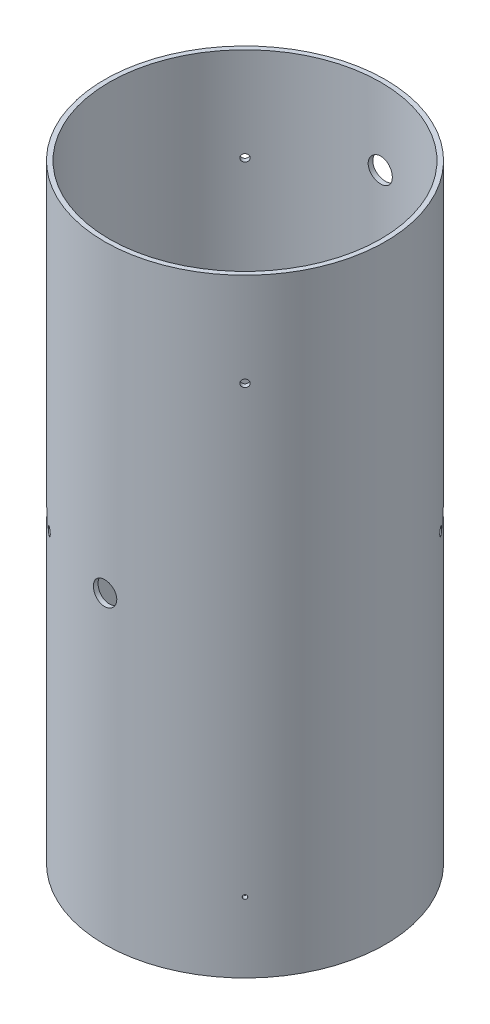
from build123d import *

# Parameters (mm, degrees)
SKETCH1_R               = 76.1746
SKETCH1_R_2             = 73.66
BOSS_EXTRUDE1_DEPTH     = 330.2
SKETCH27_R              = 6.35
CUT_EXTRUDE1_DEPTH      = 77.1746001
CUT_EXTRUDE1_DEPTH_BACK = 77.1746001
SKETCH30_R              = 2.18313
SKETCH30_W              = 9.906
SKETCH30_H              = 9.906
CUT_EXTRUDE2_DEPTH      = 108.72715257
CUT_EXTRUDE2_DEPTH_BACK = 108.72715257
SKETCH23_R              = 1.0922
SHEAR_SCRREWS_DEPTH     = 108.72715257
CIRPATTERN1_COUNT       = 4
CIRPATTERN2_COUNT       = 4


with BuildPart() as part:
    # Sketch1 → Boss-Extrude1 (new body)
    with BuildSketch(Plane(origin=(0, 0, 0), x_dir=(1, 0, 0), z_dir=(0, 1, 0))):
        Circle(SKETCH1_R)
        Circle(SKETCH1_R_2, mode=Mode.SUBTRACT)
    extrude(amount=BOSS_EXTRUDE1_DEPTH)

    # Sketch17 → 1/2 Clearance Hole5 (revolve, cut)
    with BuildSketch(Plane(origin=(0, 288.925, 0), x_dir=(0, -1, 0), z_dir=(1, 0, 0))):
        Polygon((0, 0), (0, 80.134507437), (6.54812, 76.2), (6.54812, 0), align=None)
    revolve(axis=Axis((0, 288.925, 6.35), (0, 0, -1)), mode=Mode.SUBTRACT)

    # Sketch27 → Cut-Extrude1 (cut, two sides)
    with BuildSketch(Plane.XY) as cut_extrude1_sk:
        with Locations((0, 165.1)):
            Circle(SKETCH27_R)
    extrude(amount=CUT_EXTRUDE1_DEPTH, mode=Mode.SUBTRACT)
    extrude(cut_extrude1_sk.sketch, amount=-CUT_EXTRUDE1_DEPTH_BACK, mode=Mode.SUBTRACT)

    # Sketch30 → Cut-Extrude2 (cut, two sides)
    with BuildSketch(Plane(origin=(0, 0, 0), x_dir=(0.707106781, 0, 0.707106781), z_dir=(-0.707106781, 0, 0.707106781))) as cut_extrude2_sk:
        with Locations((-12.7, 165.1)):
            Circle(SKETCH30_R)
        with Locations((12.7, 165.1)):
            Circle(SKETCH30_R)
        with Locations((0, 165.1)):
            Rectangle(SKETCH30_W, SKETCH30_H)
    extrude(amount=CUT_EXTRUDE2_DEPTH, mode=Mode.SUBTRACT)
    extrude(cut_extrude2_sk.sketch, amount=-CUT_EXTRUDE2_DEPTH_BACK, mode=Mode.SUBTRACT)

    # Sketch23 → Shear Scrrews (cut, through all)
    with BuildSketch(Plane(origin=(0, 0, 0), x_dir=(0.707106781, 0, 0.707106781), z_dir=(-0.707106781, 0, 0.707106781))):
        with Locations((0, 38.1)):
            Circle(SKETCH23_R)
    shear_scrrews = extrude(amount=-SHEAR_SCRREWS_DEPTH, mode=Mode.SUBTRACT)

    # CirPattern1: Shear Scrrews ×4 about axis
    cirpattern1_axis = Axis((0, 330.2, 0), (0, -1, 0))
    for i in range(1, CIRPATTERN1_COUNT):
        add(shear_scrrews.rotate(cirpattern1_axis, i * 360 / CIRPATTERN1_COUNT), mode=Mode.SUBTRACT)

    # Sketch25 → Ø4.0 (4) Diameter Hole1 (revolve, cut)
    with BuildSketch(Plane(origin=(0, 279.4, 0), x_dir=(-0.707106781, 0, -0.707106781), z_dir=(0, 1, 0))):
        Polygon((0, 0), (0, 90.101721238), (2, 88.9), (2, 0), align=None)
    f_4_0_4_diameter_hole1 = revolve(axis=Axis((4.490128061, 279.4, -4.490128061), (-0.707106781, 0, 0.707106781)), mode=Mode.SUBTRACT)

    # CirPattern2: Ø4.0 (4) Diameter Hole1 ×4 about axis
    cirpattern2_axis = Axis((0, 330.2, 0), (0, 1, 0))
    for i in range(1, CIRPATTERN2_COUNT):
        add(f_4_0_4_diameter_hole1.rotate(cirpattern2_axis, i * 360 / CIRPATTERN2_COUNT), mode=Mode.SUBTRACT)


solid = part.part
